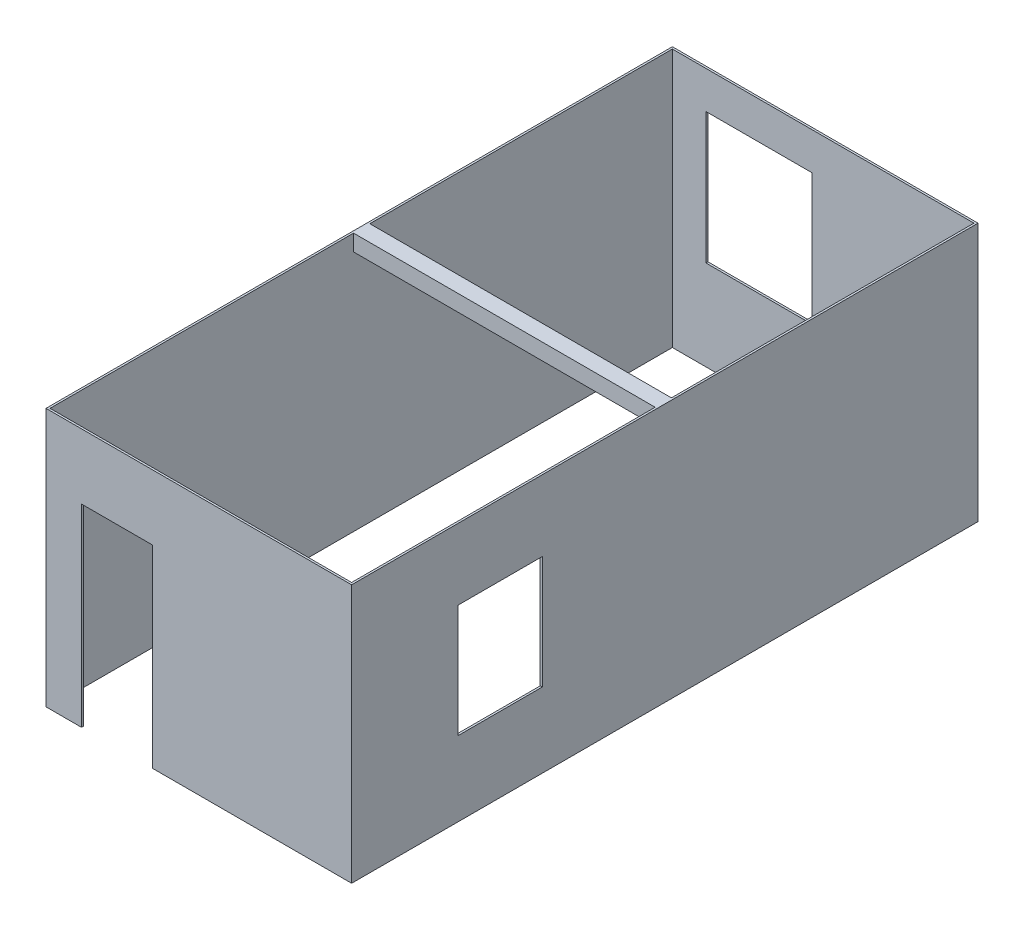
from build123d import *

# Parameters (mm, degrees)
SKETCH_1_W            = 3192
SKETCH_1_H            = 6542
SKETCH_1_W_2          = 3150
SKETCH_1_H_2          = 6500
EXTRUDE_381_DEPTH     = 2700
SKETCH_2_W            = 740
SKETCH_2_H            = 2020
CUT_EXTRUDE_622_DEPTH = 22
SKETCH_3_W            = 880
SKETCH_3_H            = 1180
CUT_EXTRUDE_1_DEPTH   = 22
SKETCH_4_W            = 1110
SKETCH_4_H            = 1370
CUT_EXTRUDE_2_DEPTH   = 22
EXTRUDE_1378_REACH    = 3173
SKETCH_5_W            = 170
SKETCH_5_H            = 170


with BuildPart() as part:
    # 草图1 → Extrude 381 (new body)
    with BuildSketch(Plane(origin=(0, 0, 0), x_dir=(1, 0, 0), z_dir=(0, 1, 0))):
        with Locations((-1575, 3250)):
            Rectangle(SKETCH_1_W, SKETCH_1_H)
        with Locations((-1575, 3250)):
            Rectangle(SKETCH_1_W_2, SKETCH_1_H_2, mode=Mode.SUBTRACT)
    extrude(amount=EXTRUDE_381_DEPTH)

    # 草图2 → Cut-Extrude 622 (cut, through all)
    with BuildSketch(Plane(origin=(0, 0, 0), x_dir=(-1, 0, 0), z_dir=(0, 0, -1))):
        with Locations((2430, 1010)):
            Rectangle(SKETCH_2_W, SKETCH_2_H)
    extrude(amount=-CUT_EXTRUDE_622_DEPTH, mode=Mode.SUBTRACT)

    # 草图3 → 窗1 (cut, through all)
    with BuildSketch(Plane.ZY):
        with Locations((-1530, 1370)):
            Rectangle(SKETCH_3_W, SKETCH_3_H)
    extrude(amount=-CUT_EXTRUDE_1_DEPTH, mode=Mode.SUBTRACT)

    # 草图4 → 窗2 (cut, through all)
    with BuildSketch(Plane.XY.offset(-6500)):
        with Locations((-2245, 1625)):
            Rectangle(SKETCH_4_W, SKETCH_4_H)
    extrude(amount=-CUT_EXTRUDE_2_DEPTH, mode=Mode.SUBTRACT)

    # 草图5 → Extrude 1378 (add, up to next)
    with BuildSketch(Plane.ZY, mode=Mode.PRIVATE) as extrude_1378_sk1:
        with Locations((-3255, 2615)):
            Rectangle(SKETCH_5_W, SKETCH_5_H)
    extrude_1378_tool1 = extrude(extrude_1378_sk1.sketch, amount=EXTRUDE_1378_REACH, mode=Mode.PRIVATE) - part.part
    add(extrude_1378_tool1.solids().sort_by_distance((0, 2615, -3255))[0])


solid = part.part
